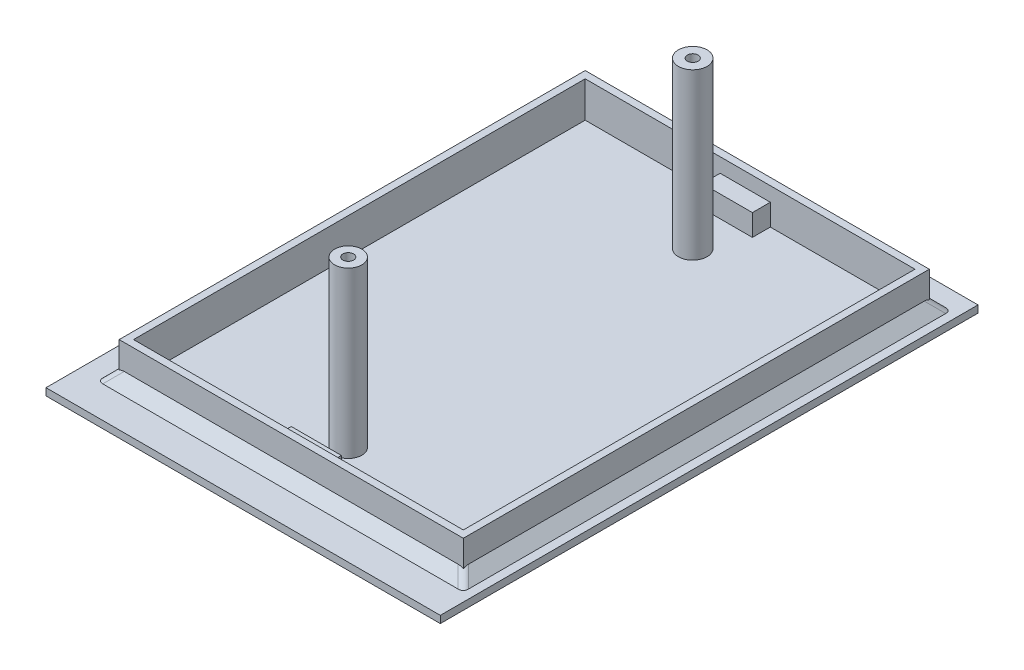
from build123d import *

# Parameters (mm, degrees)
SKETCH_1_W          = 55
SKETCH_1_H          = 75
EXTRUDE_1_DEPTH     = 1
SKETCH_3_W          = 48
SKETCH_3_H          = 65
SKETCH_3_W_2        = 46
SKETCH_3_H_2        = 63
EXTRUDE_2_DEPTH     = 5
SKETCH_4_W          = 7
SKETCH_4_H          = 2.5
EXTRUDE_3_DEPTH     = 3
SKETCH_5_R          = 1.9
EXTRUDE_4_DEPTH     = 23
SKETCH_6_R          = 0.75
CUT_EXTRUDE_1_DEPTH = 10
SKETCH_7_R          = 2
EXTRUDE_5_DEPTH     = 23
SKETCH_8_R          = 0.75
CUT_EXTRUDE_2_DEPTH = 10
CHAMFER_1_SIZE      = 1.5
FILLET_2_R          = 1


with BuildPart() as part:
    # Эскиз1 → Бобышка-Вытянуть1 (new body)
    with BuildSketch(Plane(origin=(0, 0, 0), x_dir=(1, 0, 0), z_dir=(0, 1, 0))):
        with Locations((0.630718954, -16.009803922)):
            Rectangle(SKETCH_1_W, SKETCH_1_H)
    extrude(amount=-EXTRUDE_1_DEPTH)

    # Эскиз3 → Бобышка-Вытянуть2 (add)
    with BuildSketch(Plane(origin=(0, 0, 0), x_dir=(1, 0, 0), z_dir=(0, 1, 0))):
        with Locations((1.423879909, -15.093947699)):
            Rectangle(SKETCH_3_W, SKETCH_3_H)
        with Locations((1.423879909, -15.093947699)):
            Rectangle(SKETCH_3_W_2, SKETCH_3_H_2, mode=Mode.SUBTRACT)
    extrude(amount=EXTRUDE_2_DEPTH)

    # Эскиз4 → Бобышка-Вытянуть3 (add)
    with BuildSketch(Plane(origin=(0, 0, 0), x_dir=(1, 0, 0), z_dir=(0, 1, 0))):
        with Locations((1.423879909, -45.343947699)):
            Rectangle(SKETCH_4_W, SKETCH_4_H)
        with Locations((0.74590962, 15.156052301)):
            Rectangle(SKETCH_4_W, SKETCH_4_H)
    extrude(amount=EXTRUDE_3_DEPTH)

    # Эскиз5 → Бобышка-Вытянуть4 (add)
    with BuildSketch(Plane(origin=(0, 0, 0), x_dir=(1, 0, 0), z_dir=(0, 1, 0))):
        with Locations((1.423879909, -39.643947699)):
            Circle(SKETCH_5_R)
    extrude(amount=EXTRUDE_4_DEPTH)

    # Эскиз6 → Вырез-Вытянуть1 (cut)
    with BuildSketch(Plane(origin=(0, 23, 0), x_dir=(1, 0, 0), z_dir=(0, 1, 0))):
        with Locations((1.423879909, -39.643947699)):
            Circle(SKETCH_6_R)
    extrude(amount=-CUT_EXTRUDE_1_DEPTH, mode=Mode.SUBTRACT)

    # Эскиз7 → Бобышка-Вытянуть5 (add)
    with BuildSketch(Plane(origin=(0, 0, 0), x_dir=(1, 0, 0), z_dir=(0, 1, 0))):
        with Locations((1.423879909, 8.406052301)):
            Circle(SKETCH_7_R)
    extrude(amount=EXTRUDE_5_DEPTH)

    # Эскиз8 → Вырез-Вытянуть2 (cut)
    with BuildSketch(Plane(origin=(0, 23, 0), x_dir=(1, 0, 0), z_dir=(0, 1, 0))):
        with Locations((1.423879909, 8.406052301)):
            Circle(SKETCH_8_R)
    extrude(amount=-CUT_EXTRUDE_2_DEPTH, mode=Mode.SUBTRACT)

    # Фаска1
    chamfer_1_edges = [part.edges().sort_by_distance(p)[0] for p in [
        (-22.576120091, 0, 15.093947699),
        (1.423879909, 0, 47.593947699),
        (25.423879909, 0, 15.093947699),
        (1.423879909, 0, -17.406052301),
    ]]
    chamfer(chamfer_1_edges, length=CHAMFER_1_SIZE)

    # Скругление2
    fillet_2_edges = [part.edges().sort_by_distance(p)[0] for p in [
        (-23.326120091, 0.75, -18.156052301),
        (26.173879909, 0.75, -18.156052301),
        (-23.326120091, 0.75, 48.343947699),
        (26.173879909, 0.75, 48.343947699),
    ]]
    fillet(fillet_2_edges, radius=FILLET_2_R)


solid = part.part
